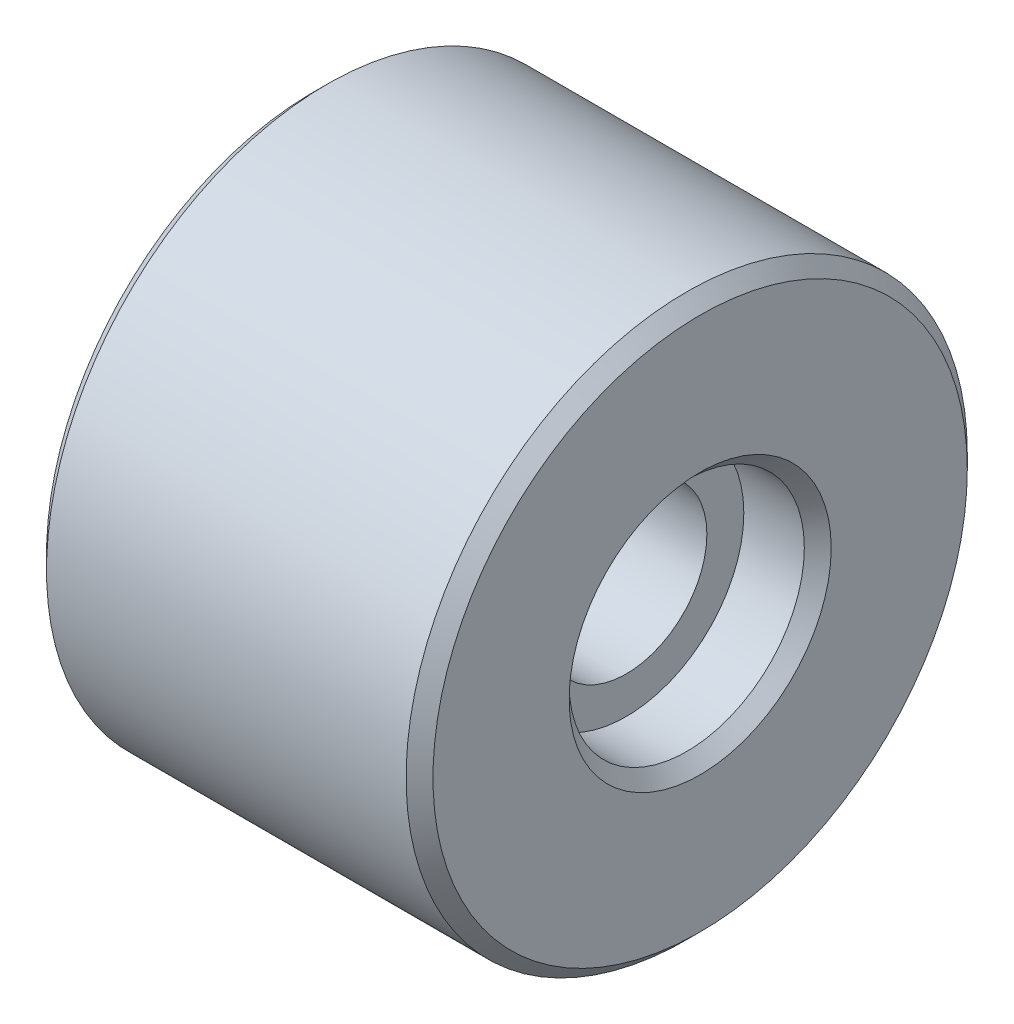
from build123d import *

# Parameters (mm, degrees)
SKETCH_1_R          = 8.35
SKETCH_1_R_2        = 2.4
EXTRUDE_1_DEPTH     = 11.5
SKETCH_2_R          = 3.5
CUT_EXTRUDE_1_DEPTH = 2.2
CHAMFER_1_SIZE      = 0.4


with BuildPart() as part:
    # 草图1 → 凸台-拉伸1 (new body)
    with BuildSketch(Plane(origin=(0, 0, 0), x_dir=(0, 0, -1), z_dir=(1, 0, 0))):
        Circle(SKETCH_1_R)
        Circle(SKETCH_1_R_2, mode=Mode.SUBTRACT)
    extrude(amount=EXTRUDE_1_DEPTH)

    # 草图2 → 切除-拉伸1 (cut)
    with BuildSketch(Plane(origin=(11.5, 0, 0), x_dir=(0, 0, -1), z_dir=(1, 0, 0))):
        Circle(SKETCH_2_R)
    extrude(amount=-CUT_EXTRUDE_1_DEPTH, mode=Mode.SUBTRACT)

    # 倒角1
    chamfer_1_edges = [part.edges().sort_by_distance(p)[0] for p in [
        (11.5, 0, 3.5),
        (0, 0, 8.35),
        (11.5, 0, 8.35),
        (0, 0, 2.4),
    ]]
    chamfer(chamfer_1_edges, length=CHAMFER_1_SIZE)


solid = part.part
